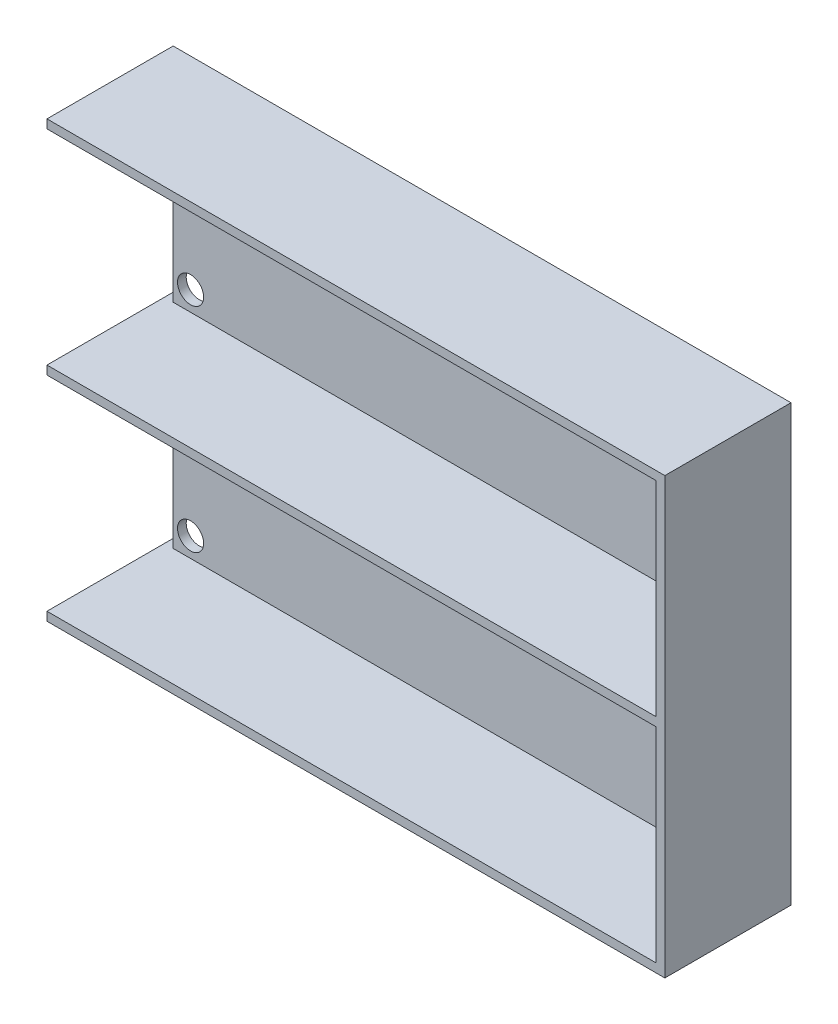
from build123d import *

# Parameters (mm, degrees)
SKETCH1_W           = 142
SKETCH1_H           = 100
BOSS_EXTRUDE1_DEPTH = 2
BOSS_EXTRUDE2_DEPTH = 27
SKETCH4_W           = 2
SKETCH4_H           = 47
CUT_EXTRUDE1_DEPTH  = 3
SKETCH5_R           = 3
CUT_EXTRUDE4_DEPTH  = 30


with BuildPart() as part:
    # Sketch1 → Boss-Extrude1 (new body)
    with BuildSketch(Plane.XY):
        with Locations((8.448668202, -3.21033452)):
            Rectangle(SKETCH1_W, SKETCH1_H)
    extrude(amount=BOSS_EXTRUDE1_DEPTH)

    # Sketch3 → Boss-Extrude2 (add)
    with BuildSketch(Plane.XY.offset(2)):
        Polygon((-62.551331798, -53.21033452), (79.448668202, -53.21033452), (79.448668202, 46.78966548), (-62.551331798, 46.78966548), (-62.551331798, 44.78966548), (77.448668202, 44.78966548), (77.448668202, -2.21033452), (-62.551331798, -2.21033452), (-62.551331798, -4.21033452), (77.448668202, -4.21033452), (77.448668202, -51.21033452), (-62.551331798, -51.21033452), align=None)
    extrude(amount=BOSS_EXTRUDE2_DEPTH)

    # Sketch4 → Cut-Extrude1 (cut, through all)
    with BuildSketch(Plane.XY.offset(2)):
        with Locations((-61.551331798, 21.28966548)):
            Rectangle(SKETCH4_W, SKETCH4_H)
        with Locations((-61.551331798, -27.71033452)):
            Rectangle(SKETCH4_W, SKETCH4_H)
    extrude(amount=-CUT_EXTRUDE1_DEPTH, mode=Mode.SUBTRACT)

    # Sketch5 → Cut-Extrude4 (cut, through all)
    with BuildSketch(Plane(origin=(0, 0, 0), x_dir=(-1, 0, 0), z_dir=(0, 0, -1))):
        with Locations((56.551331798, 40.28966548)):
            Circle(SKETCH5_R)
        with Locations((56.551331798, 2.28966548)):
            Circle(SKETCH5_R)
        with Locations((56.551331798, -8.71033452)):
            Circle(SKETCH5_R)
        with Locations((56.551331798, -46.71033452)):
            Circle(SKETCH5_R)
    extrude(amount=-CUT_EXTRUDE4_DEPTH, mode=Mode.SUBTRACT)


solid = part.part
